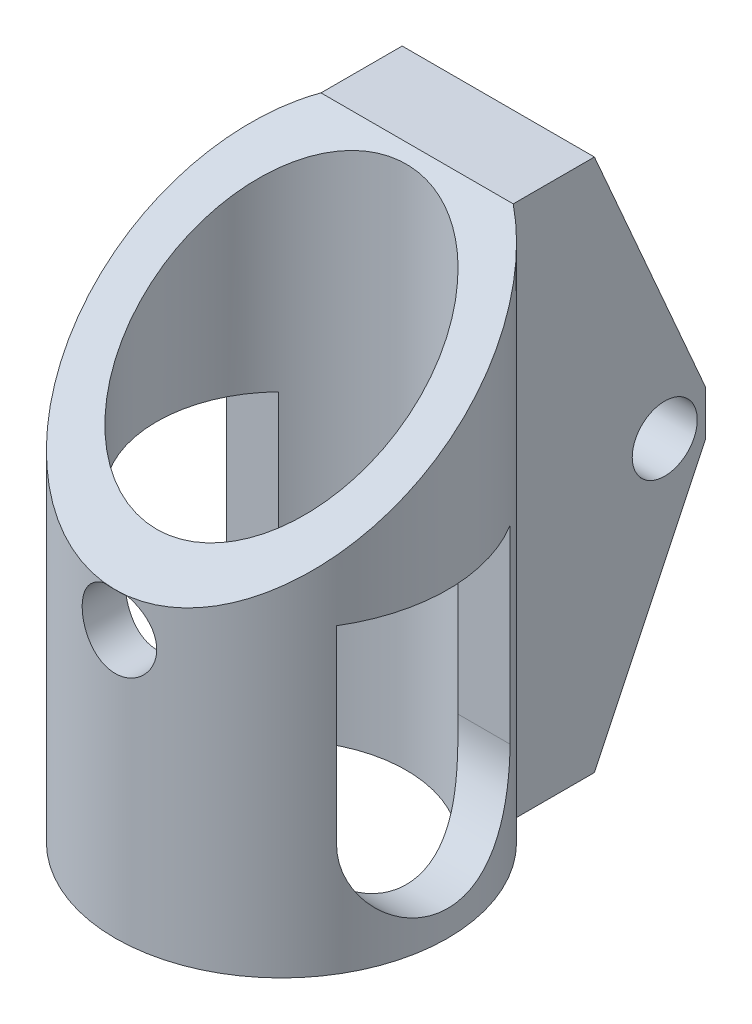
from build123d import *

# Parameters (mm, degrees)
SKETCH1_R           = 11.5
SKETCH1_R_2         = 8.6383
BOSS_EXTRUDE1_DEPTH = 36.88
CUT_EXTRUDE1_DEPTH  = 55.88
SKETCH3_R           = 2.5796875
CUT_EXTRUDE2_DEPTH  = 12.5000001
BOSS_EXTRUDE2_START = -15
SKETCH4_W           = 13.2990488
SKETCH4_H           = 36.88
BOSS_EXTRUDE2_DEPTH = 5.617366
SKETCH5_R           = 2.25
BOSS_EXTRUDE3_DEPTH = 13.299049
SKETCH6_W           = 23.727033019
SKETCH6_H           = 15.887615844
CUT_EXTRUDE3_DEPTH  = 15
SKETCH7_R           = 11.5
SKETCH7_R_2         = 8.6383
BOSS_EXTRUDE4_DEPTH = 1
SKETCH8_R           = 11.5
SKETCH8_R_2         = 8.6383
BOSS_EXTRUDE5_DEPTH = 15
CUT_EXTRUDE4_DEPTH  = 24.0000001


with BuildPart() as part:
    # Sketch1 → Boss-Extrude1 (new body)
    with BuildSketch(Plane(origin=(0, 0, 0), x_dir=(1, 0, 0), z_dir=(0, 1, 0))):
        Circle(SKETCH1_R)
        Circle(SKETCH1_R_2, mode=Mode.SUBTRACT)
    extrude(amount=BOSS_EXTRUDE1_DEPTH)

    # Sketch2 → Cut-Extrude1 (cut)
    with BuildSketch(Plane.ZY.offset(11.5)):
        with BuildLine():
            Line((6, 29.09589156), (6, 7.78410844))
            ThreePointArc((6, 7.78410844), (0, 1.78410844), (-6, 7.78410844))
            Line((-6, 7.78410844), (-6, 29.09589156))
            ThreePointArc((-6, 29.09589156), (0, 35.09589156), (6, 29.09589156))
        make_face()
    extrude(amount=-CUT_EXTRUDE1_DEPTH, mode=Mode.SUBTRACT)

    # Sketch3 → Cut-Extrude2 (cut, through all)
    with BuildSketch(Plane.XY):
        with Locations((0, 18.44)):
            Circle(SKETCH3_R)
    extrude(amount=CUT_EXTRUDE2_DEPTH, mode=Mode.SUBTRACT)

    # Sketch4 → Boss-Extrude2 (add)
    with BuildSketch(Plane.XY.offset(BOSS_EXTRUDE2_START)):
        with Locations((0, 18.44)):
            Rectangle(SKETCH4_W, SKETCH4_H)
    extrude(amount=BOSS_EXTRUDE2_DEPTH)

    # Sketch5 → Boss-Extrude3 (add)
    with BuildSketch(Plane.ZY.offset(6.6495244)):
        Polygon((-22.694041563, 16.13624889), (-22.694041563, 19.233959607), (-15, 36.88), (-15, 0), align=None)
        with Locations((-19.865413399, 17.576967072)):
            Circle(SKETCH5_R, mode=Mode.SUBTRACT)
    extrude(amount=-BOSS_EXTRUDE3_DEPTH)

    # Sketch6 → Cut-Extrude3 (cut)
    with BuildSketch(Plane(origin=(0, 36.88, 0), x_dir=(1, 0, 0), z_dir=(0, 1, 0))):
        with Locations((0.120731314, -4.641807922)):
            Rectangle(SKETCH6_W, SKETCH6_H)
    extrude(amount=-CUT_EXTRUDE3_DEPTH, mode=Mode.SUBTRACT)

    # Sketch7 → Boss-Extrude4 (add)
    with BuildSketch(Plane(origin=(0, 21.88, 0), x_dir=(1, 0, 0), z_dir=(0, 1, 0))):
        Circle(SKETCH7_R)
        Circle(SKETCH7_R_2, mode=Mode.SUBTRACT)
    extrude(amount=-BOSS_EXTRUDE4_DEPTH)

    # Sketch8 → Boss-Extrude5 (add)
    with BuildSketch(Plane(origin=(0, 21.88, 0), x_dir=(1, 0, 0), z_dir=(0, 1, 0))):
        Circle(SKETCH8_R)
        Circle(SKETCH8_R_2, mode=Mode.SUBTRACT)
    extrude(amount=BOSS_EXTRUDE5_DEPTH)

    # Sketch9 → Cut-Extrude4 (cut, through all)
    with BuildSketch(Plane.ZY.offset(11.5)):
        Polygon((-9.382634239, 36.88), (11.5, 20.88), (11.5, 36.88), align=None)
    extrude(amount=-CUT_EXTRUDE4_DEPTH, mode=Mode.SUBTRACT)


solid = part.part
